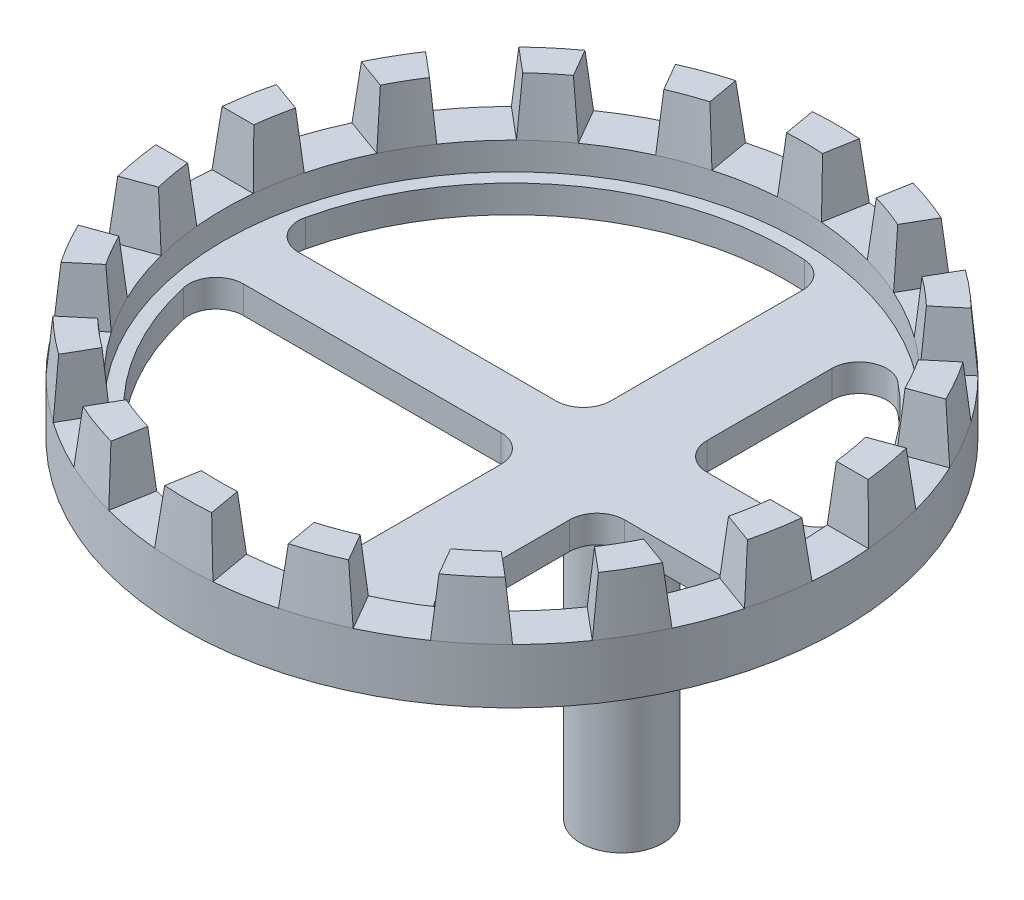
from build123d import *

# Parameters (mm, degrees)
SKETCH1_R                 = 60
SKETCH1_R_2               = 7.5
BOSS_EXTRUDE1_DEPTH       = 5
SKETCH1_3_R               = 7.5
BOSS_EXTRUDE2_DEPTH       = 50
CUT_EXTRUDE1_DEPTH        = 5
SKETCH3_R                 = 60
SKETCH3_R_2               = 52.5
BOSS_EXTRUDE3_DEPTH       = 5
BOSS_EXTRUDE4_DEPTH       = 10
BOSS_EXTRUDE4_DRAFT       = 5
CIRPATTERN1_COPY_1_DEPTH  = 10
CIRPATTERN1_COPY_1_DRAFT  = 5
CIRPATTERN1_COPY_2_DEPTH  = 10
CIRPATTERN1_COPY_2_DRAFT  = 5
CIRPATTERN1_COPY_3_DEPTH  = 10
CIRPATTERN1_COPY_3_DRAFT  = 5
CIRPATTERN1_COPY_4_DEPTH  = 10
CIRPATTERN1_COPY_4_DRAFT  = 5
CIRPATTERN1_COPY_5_DEPTH  = 10
CIRPATTERN1_COPY_5_DRAFT  = 5
CIRPATTERN1_COPY_6_DEPTH  = 10
CIRPATTERN1_COPY_6_DRAFT  = 5
CIRPATTERN1_COPY_7_DEPTH  = 10
CIRPATTERN1_COPY_7_DRAFT  = 5
CIRPATTERN1_COPY_8_DEPTH  = 10
CIRPATTERN1_COPY_8_DRAFT  = 5
CIRPATTERN1_COPY_9_DEPTH  = 10
CIRPATTERN1_COPY_9_DRAFT  = 5
CIRPATTERN1_COPY_10_DEPTH = 10
CIRPATTERN1_COPY_10_DRAFT = 5
CIRPATTERN1_COPY_11_DEPTH = 10
CIRPATTERN1_COPY_11_DRAFT = 5
CIRPATTERN1_COPY_12_DEPTH = 10
CIRPATTERN1_COPY_12_DRAFT = 5
CIRPATTERN1_COPY_13_DEPTH = 10
CIRPATTERN1_COPY_13_DRAFT = 5
CIRPATTERN1_COPY_14_DEPTH = 10
CIRPATTERN1_COPY_14_DRAFT = 5
CIRPATTERN1_COPY_15_DEPTH = 10
CIRPATTERN1_COPY_15_DRAFT = 5
CIRPATTERN1_COPY_16_DEPTH = 10
CIRPATTERN1_COPY_16_DRAFT = 5
CIRPATTERN1_COPY_17_DEPTH = 10
CIRPATTERN1_COPY_17_DRAFT = 5


with BuildPart() as part:
    # Sketch1 → Boss-Extrude1 (new body)
    with BuildSketch(Plane(origin=(0, 0, 0), x_dir=(1, 0, 0), z_dir=(0, 1, 0))):
        with Locations(Location((-20, 0, 0), (0, 0, 270))):
            Circle(SKETCH1_R)
        Circle(SKETCH1_R_2, mode=Mode.SUBTRACT)
        Circle(SKETCH1_R_2)
    extrude(amount=BOSS_EXTRUDE1_DEPTH)

    # Sketch1_3 → Boss-Extrude2 (add)
    with BuildSketch(Plane(origin=(0, 0, 0), x_dir=(1, 0, 0), z_dir=(0, 1, 0))):
        with Locations(Location((0, 0, 0), (0, 0, 270))):
            Circle(SKETCH1_3_R)
    extrude(amount=-BOSS_EXTRUDE2_DEPTH)

    # Sketch2 → Cut-Extrude1 (cut)
    with BuildSketch(Plane(origin=(0, 5, 0), x_dir=(1, 0, 0), z_dir=(0, 1, 0))):
        with BuildLine():
            Line((3, 35.227829908), (3, 12.5))
            ThreePointArc((3, 12.5), (4.464466094, 8.964466094), (8, 7.5))
            Line((8, 7.5), (23.229041164, 7.5))
            ThreePointArc((23.229041164, 7.5), (27.225567434, 9.495373937), (28.032267961, 13.888888889))
            ThreePointArc((28.032267961, 13.888888889), (21.537319816, 27.832554006), (11.111111111, 39.142033231))
            ThreePointArc((11.111111111, 39.142033231), (5.826932532, 39.73091527), (3, 35.227829908))
        make_face()
        with BuildLine():
            Line((-12, 44.899888641), (-12, 10))
            ThreePointArc((-12, 10), (-13.464466094, 6.464466094), (-17, 5))
            Line((-17, 5), (-63.874821937, 5))
            ThreePointArc((-63.874821937, 5), (-67.783501737, 6.881952178), (-68.749802152, 11.111111111))
            ThreePointArc((-68.749802152, 11.111111111), (-49.859513113, 40.104980697), (-16.666666667, 49.888765157))
            ThreePointArc((-16.666666667, 49.888765157), (-13.348516283, 48.315538897), (-12, 44.899888641))
        make_face()
        with BuildLine():
            Line((-17, -5), (-63.874821937, -5))
            ThreePointArc((-63.874821937, -5), (-67.783501737, -6.881952178), (-68.749802152, -11.111111111))
            ThreePointArc((-68.749802152, -11.111111111), (-49.859513113, -40.104980697), (-16.666666667, -49.888765157))
            ThreePointArc((-16.666666667, -49.888765157), (-13.348516283, -48.315538897), (-12, -44.899888641))
            Line((-12, -44.899888641), (-12, -10))
            ThreePointArc((-12, -10), (-13.464466094, -6.464466094), (-17, -5))
        make_face()
        with BuildLine():
            Line((8, -7.5), (29.434299833, -7.5))
            ThreePointArc((29.434299833, -7.5), (23.268873024, -25.056029758), (11.111111111, -39.142033231))
            ThreePointArc((11.111111111, -39.142033231), (5.826932532, -39.73091527), (3, -35.227829908))
            Line((3, -35.227829908), (3, -12.5))
            ThreePointArc((3, -12.5), (4.464466094, -8.964466094), (8, -7.5))
        make_face()
    extrude(amount=-CUT_EXTRUDE1_DEPTH, mode=Mode.SUBTRACT)

    # Sketch3 → Boss-Extrude3 (add)
    with BuildSketch(Plane(origin=(0, 5, 0), x_dir=(1, 0, 0), z_dir=(0, 1, 0))):
        with Locations(Location((-20, 0, 0), (0, 0, 270))):
            Circle(SKETCH3_R)
        with Locations(Location((-20, 0, 0), (0, 0, 270))):
            Circle(SKETCH3_R_2, mode=Mode.SUBTRACT)
    extrude(amount=BOSS_EXTRUDE3_DEPTH)


with BuildPart() as boss_extrude4_tool:
    # Sketch4 → Boss-Extrude4 (with draft: the straight prism first)
    with BuildSketch(Plane(origin=(0, 10, 0), x_dir=(1, 0, 0), z_dir=(0, 1, 0))):
        with BuildLine():
            Line((-25.307880973, 59.764758843), (-24, 52.347397261))
            ThreePointArc((-24, 52.347397261), (-20, 52.5), (-16, 52.347397261))
            Line((-16, 52.347397261), (-14.692119027, 59.764758843))
            ThreePointArc((-14.692119027, 59.764758843), (-20, 60), (-25.307880973, 59.764758843))
        make_face()
    extrude(amount=BOSS_EXTRUDE4_DEPTH)
    # Boss-Extrude4: the draft: its side faces are tilted about the plane it starts from
    boss_extrude4_sides = [boss_extrude4_tool.faces().sort_by_distance(p)[0] for p in [
        (-15.346059514, 15, -56.056078052),
        (-20, 15, -60),
        (-24.653940486, 15, -56.056078052),
        (-20, 15, -52.5),
    ]]
    draft(boss_extrude4_sides, Plane(origin=(0, 10, 0), x_dir=(1, 0, 0), z_dir=(0, 1, 0)), BOSS_EXTRUDE4_DRAFT)


with BuildPart() as part_1:
    add(part.part)

    # Boss-Extrude4: add boss_extrude4_tool
    add(boss_extrude4_tool.part)


with BuildPart() as cirpattern1_copy_1_tool:
    # CirPattern1 copy 1 sketch → CirPattern1 copy 1 (with draft: the straight prism first)
    with BuildSketch(Plane(origin=(-1.206147584, 10, -6.840402867), x_dir=(0.9396926207859084, 0, -0.3420201433256687), z_dir=(0, 1, 0))):
        with BuildLine():
            Line((-25.307880973, 59.764758843), (-24, 52.347397261))
            ThreePointArc((-24, 52.347397261), (-20, 52.5), (-16, 52.347397261))
            Line((-16, 52.347397261), (-14.692119027, 59.764758843))
            ThreePointArc((-14.692119027, 59.764758843), (-20, 60), (-25.307880973, 59.764758843))
        make_face()
    extrude(amount=CIRPATTERN1_COPY_1_DEPTH)
    # CirPattern1 copy 1: the draft: its side faces are tilted about the plane it starts from
    cirpattern1_copy_1_sides = [cirpattern1_copy_1_tool.faces().sort_by_distance(p)[0] for p in [
        (-34.799034317, 15, -54.267224288),
        (-40.5212086, 15, -56.381557247),
        (-43.545581382, 15, -51.083741504),
        (-37.956057525, 15, -49.333862591),
    ]]
    draft(cirpattern1_copy_1_sides, Plane(origin=(-1.206147584, 10, -6.840402867), x_dir=(0.9396926207859084, 0, -0.3420201433256687), z_dir=(0, 1, 0)), CIRPATTERN1_COPY_1_DRAFT)


with BuildPart() as part_2:
    add(part_1.part)

    # CirPattern1 copy 1: add cirpattern1_copy_1_tool
    add(cirpattern1_copy_1_tool.part)


with BuildPart() as cirpattern1_copy_2_tool:
    # CirPattern1 copy 2 sketch → CirPattern1 copy 2 (with draft: the straight prism first)
    with BuildSketch(Plane(origin=(-4.679111138, 10, -12.855752194), x_dir=(0.766044443118978, 0, -0.6427876096865393), z_dir=(0, 1, 0))):
        with BuildLine():
            Line((-25.307880973, 59.764758843), (-24, 52.347397261))
            ThreePointArc((-24, 52.347397261), (-20, 52.5), (-16, 52.347397261))
            Line((-16, 52.347397261), (-14.692119027, 59.764758843))
            ThreePointArc((-14.692119027, 59.764758843), (-20, 60), (-25.307880973, 59.764758843))
        make_face()
    extrude(amount=CIRPATTERN1_COPY_2_DEPTH)
    # CirPattern1 copy 2: the draft: its side faces are tilted about the plane it starts from
    cirpattern1_copy_2_sides = [cirpattern1_copy_2_tool.faces().sort_by_distance(p)[0] for p in [
        (-52.467027172, 15, -45.932942375),
        (-58.567256581, 15, -45.962666587),
        (-59.597277667, 15, -39.949951814),
        (-53.746349509, 15, -40.217333264),
    ]]
    draft(cirpattern1_copy_2_sides, Plane(origin=(-4.679111138, 10, -12.855752194), x_dir=(0.766044443118978, 0, -0.6427876096865393), z_dir=(0, 1, 0)), CIRPATTERN1_COPY_2_DRAFT)


with BuildPart() as part_3:
    add(part_2.part)

    # CirPattern1 copy 2: add cirpattern1_copy_2_tool
    add(cirpattern1_copy_2_tool.part)


with BuildPart() as cirpattern1_copy_3_tool:
    # CirPattern1 copy 3 sketch → CirPattern1 copy 3 (with draft: the straight prism first)
    with BuildSketch(Plane(origin=(-10, 10, -17.320508076), x_dir=(0.5000000000000001, 0, -0.8660254037844386), z_dir=(0, 1, 0))):
        with BuildLine():
            Line((-25.307880973, 59.764758843), (-24, 52.347397261))
            ThreePointArc((-24, 52.347397261), (-20, 52.5), (-16, 52.347397261))
            Line((-16, 52.347397261), (-14.692119027, 59.764758843))
            ThreePointArc((-14.692119027, 59.764758843), (-20, 60), (-25.307880973, 59.764758843))
        make_face()
    extrude(amount=CIRPATTERN1_COPY_3_DEPTH)
    # CirPattern1 copy 3: the draft: its side faces are tilted about the plane it starts from
    cirpattern1_copy_3_sides = [cirpattern1_copy_3_tool.faces().sort_by_distance(p)[0] for p in [
        (-66.219017387, 15, -32.058469715),
        (-71.961524227, 15, -30),
        (-70.872957873, 15, -23.997608337),
        (-65.466333699, 15, -26.25),
    ]]
    draft(cirpattern1_copy_3_sides, Plane(origin=(-10, 10, -17.320508076), x_dir=(0.5000000000000001, 0, -0.8660254037844386), z_dir=(0, 1, 0)), CIRPATTERN1_COPY_3_DRAFT)


with BuildPart() as part_4:
    add(part_3.part)

    # CirPattern1 copy 3: add cirpattern1_copy_3_tool
    add(cirpattern1_copy_3_tool.part)


with BuildPart() as cirpattern1_copy_4_tool:
    # CirPattern1 copy 4 sketch → CirPattern1 copy 4 (with draft: the straight prism first)
    with BuildSketch(Plane(origin=(-16.527036447, 10, -19.69615506), x_dir=(0.17364817766693041, 0, -0.984807753012208), z_dir=(0, 1, 0))):
        with BuildLine():
            Line((-25.307880973, 59.764758843), (-24, 52.347397261))
            ThreePointArc((-24, 52.347397261), (-20, 52.5), (-16, 52.347397261))
            Line((-16, 52.347397261), (-14.692119027, 59.764758843))
            ThreePointArc((-14.692119027, 59.764758843), (-20, 60), (-25.307880973, 59.764758843))
        make_face()
    extrude(amount=CIRPATTERN1_COPY_4_DEPTH)
    # CirPattern1 copy 4: the draft: its side faces are tilted about the plane it starts from
    cirpattern1_copy_4_sides = [cirpattern1_copy_4_tool.faces().sort_by_distance(p)[0] for p in [
        (-74.396311985, 15, -14.317272474),
        (-79.088465181, 15, -10.41889066),
        (-76.012608553, 15, -5.150799128),
        (-71.702407033, 15, -9.116529328),
    ]]
    draft(cirpattern1_copy_4_sides, Plane(origin=(-16.527036447, 10, -19.69615506), x_dir=(0.17364817766693041, 0, -0.984807753012208), z_dir=(0, 1, 0)), CIRPATTERN1_COPY_4_DRAFT)


with BuildPart() as part_5:
    add(part_4.part)

    # CirPattern1 copy 4: add cirpattern1_copy_4_tool
    add(cirpattern1_copy_4_tool.part)


with BuildPart() as cirpattern1_copy_5_tool:
    # CirPattern1 copy 5 sketch → CirPattern1 copy 5 (with draft: the straight prism first)
    with BuildSketch(Plane(origin=(-23.472963553, 10, -19.69615506), x_dir=(-0.1736481776669303, 0, -0.984807753012208), z_dir=(0, 1, 0))):
        with BuildLine():
            Line((-25.307880973, 59.764758843), (-24, 52.347397261))
            ThreePointArc((-24, 52.347397261), (-20, 52.5), (-16, 52.347397261))
            Line((-16, 52.347397261), (-14.692119027, 59.764758843))
            ThreePointArc((-14.692119027, 59.764758843), (-20, 60), (-25.307880973, 59.764758843))
        make_face()
    extrude(amount=CIRPATTERN1_COPY_5_DEPTH)
    # CirPattern1 copy 5: the draft: its side faces are tilted about the plane it starts from
    cirpattern1_copy_5_sides = [cirpattern1_copy_5_tool.faces().sort_by_distance(p)[0] for p in [
        (-76.012608553, 15, 5.150799128),
        (-79.088465181, 15, 10.41889066),
        (-74.396311985, 15, 14.317272474),
        (-71.702407033, 15, 9.116529328),
    ]]
    draft(cirpattern1_copy_5_sides, Plane(origin=(-23.472963553, 10, -19.69615506), x_dir=(-0.1736481776669303, 0, -0.984807753012208), z_dir=(0, 1, 0)), CIRPATTERN1_COPY_5_DRAFT)


with BuildPart() as part_6:
    add(part_5.part)

    # CirPattern1 copy 5: add cirpattern1_copy_5_tool
    add(cirpattern1_copy_5_tool.part)


with BuildPart() as cirpattern1_copy_6_tool:
    # CirPattern1 copy 6 sketch → CirPattern1 copy 6 (with draft: the straight prism first)
    with BuildSketch(Plane(origin=(-30, 10, -17.320508076), x_dir=(-0.4999999999999998, 0, -0.8660254037844387), z_dir=(0, 1, 0))):
        with BuildLine():
            Line((-25.307880973, 59.764758843), (-24, 52.347397261))
            ThreePointArc((-24, 52.347397261), (-20, 52.5), (-16, 52.347397261))
            Line((-16, 52.347397261), (-14.692119027, 59.764758843))
            ThreePointArc((-14.692119027, 59.764758843), (-20, 60), (-25.307880973, 59.764758843))
        make_face()
    extrude(amount=CIRPATTERN1_COPY_6_DEPTH)
    # CirPattern1 copy 6: the draft: its side faces are tilted about the plane it starts from
    cirpattern1_copy_6_sides = [cirpattern1_copy_6_tool.faces().sort_by_distance(p)[0] for p in [
        (-70.872957873, 15, 23.997608337),
        (-71.961524227, 15, 30),
        (-66.219017387, 15, 32.058469715),
        (-65.466333699, 15, 26.25),
    ]]
    draft(cirpattern1_copy_6_sides, Plane(origin=(-30, 10, -17.320508076), x_dir=(-0.4999999999999998, 0, -0.8660254037844387), z_dir=(0, 1, 0)), CIRPATTERN1_COPY_6_DRAFT)


with BuildPart() as part_7:
    add(part_6.part)

    # CirPattern1 copy 6: add cirpattern1_copy_6_tool
    add(cirpattern1_copy_6_tool.part)


with BuildPart() as cirpattern1_copy_7_tool:
    # CirPattern1 copy 7 sketch → CirPattern1 copy 7 (with draft: the straight prism first)
    with BuildSketch(Plane(origin=(-35.320888862, 10, -12.855752194), x_dir=(-0.7660444431189779, 0, -0.6427876096865395), z_dir=(0, 1, 0))):
        with BuildLine():
            Line((-25.307880973, 59.764758843), (-24, 52.347397261))
            ThreePointArc((-24, 52.347397261), (-20, 52.5), (-16, 52.347397261))
            Line((-16, 52.347397261), (-14.692119027, 59.764758843))
            ThreePointArc((-14.692119027, 59.764758843), (-20, 60), (-25.307880973, 59.764758843))
        make_face()
    extrude(amount=CIRPATTERN1_COPY_7_DEPTH)
    # CirPattern1 copy 7: the draft: its side faces are tilted about the plane it starts from
    cirpattern1_copy_7_sides = [cirpattern1_copy_7_tool.faces().sort_by_distance(p)[0] for p in [
        (-59.597277667, 15, 39.949951814),
        (-58.567256581, 15, 45.962666587),
        (-52.467027172, 15, 45.932942375),
        (-53.746349509, 15, 40.217333264),
    ]]
    draft(cirpattern1_copy_7_sides, Plane(origin=(-35.320888862, 10, -12.855752194), x_dir=(-0.7660444431189779, 0, -0.6427876096865395), z_dir=(0, 1, 0)), CIRPATTERN1_COPY_7_DRAFT)


with BuildPart() as part_8:
    add(part_7.part)

    # CirPattern1 copy 7: add cirpattern1_copy_7_tool
    add(cirpattern1_copy_7_tool.part)


with BuildPart() as cirpattern1_copy_8_tool:
    # CirPattern1 copy 8 sketch → CirPattern1 copy 8 (with draft: the straight prism first)
    with BuildSketch(Plane(origin=(-38.793852416, 10, -6.840402867), x_dir=(-0.9396926207859083, 0, -0.3420201433256689), z_dir=(0, 1, 0))):
        with BuildLine():
            Line((-25.307880973, 59.764758843), (-24, 52.347397261))
            ThreePointArc((-24, 52.347397261), (-20, 52.5), (-16, 52.347397261))
            Line((-16, 52.347397261), (-14.692119027, 59.764758843))
            ThreePointArc((-14.692119027, 59.764758843), (-20, 60), (-25.307880973, 59.764758843))
        make_face()
    extrude(amount=CIRPATTERN1_COPY_8_DEPTH)
    # CirPattern1 copy 8: the draft: its side faces are tilted about the plane it starts from
    cirpattern1_copy_8_sides = [cirpattern1_copy_8_tool.faces().sort_by_distance(p)[0] for p in [
        (-43.545581382, 15, 51.083741504),
        (-40.5212086, 15, 56.381557247),
        (-34.799034317, 15, 54.267224288),
        (-37.956057525, 15, 49.333862591),
    ]]
    draft(cirpattern1_copy_8_sides, Plane(origin=(-38.793852416, 10, -6.840402867), x_dir=(-0.9396926207859083, 0, -0.3420201433256689), z_dir=(0, 1, 0)), CIRPATTERN1_COPY_8_DRAFT)


with BuildPart() as part_9:
    add(part_8.part)

    # CirPattern1 copy 8: add cirpattern1_copy_8_tool
    add(cirpattern1_copy_8_tool.part)


with BuildPart() as cirpattern1_copy_9_tool:
    # CirPattern1 copy 9 sketch → CirPattern1 copy 9 (with draft: the straight prism first)
    with BuildSketch(Plane(origin=(-40, 10, 0), x_dir=(-1, 0, 0), z_dir=(0, 1, 0))):
        with BuildLine():
            Line((-25.307880973, 59.764758843), (-24, 52.347397261))
            ThreePointArc((-24, 52.347397261), (-20, 52.5), (-16, 52.347397261))
            Line((-16, 52.347397261), (-14.692119027, 59.764758843))
            ThreePointArc((-14.692119027, 59.764758843), (-20, 60), (-25.307880973, 59.764758843))
        make_face()
    extrude(amount=CIRPATTERN1_COPY_9_DEPTH)
    # CirPattern1 copy 9: the draft: its side faces are tilted about the plane it starts from
    cirpattern1_copy_9_sides = [cirpattern1_copy_9_tool.faces().sort_by_distance(p)[0] for p in [
        (-24.653940486, 15, 56.056078052),
        (-20, 15, 60),
        (-15.346059514, 15, 56.056078052),
        (-20, 15, 52.5),
    ]]
    draft(cirpattern1_copy_9_sides, Plane(origin=(-40, 10, 0), x_dir=(-1, 0, 0), z_dir=(0, 1, 0)), CIRPATTERN1_COPY_9_DRAFT)


with BuildPart() as part_10:
    add(part_9.part)

    # CirPattern1 copy 9: add cirpattern1_copy_9_tool
    add(cirpattern1_copy_9_tool.part)


with BuildPart() as cirpattern1_copy_10_tool:
    # CirPattern1 copy 10 sketch → CirPattern1 copy 10 (with draft: the straight prism first)
    with BuildSketch(Plane(origin=(-38.793852416, 10, 6.840402867), x_dir=(-0.9396926207859084, 0, 0.34202014332566866), z_dir=(0, 1, 0))):
        with BuildLine():
            Line((-25.307880973, 59.764758843), (-24, 52.347397261))
            ThreePointArc((-24, 52.347397261), (-20, 52.5), (-16, 52.347397261))
            Line((-16, 52.347397261), (-14.692119027, 59.764758843))
            ThreePointArc((-14.692119027, 59.764758843), (-20, 60), (-25.307880973, 59.764758843))
        make_face()
    extrude(amount=CIRPATTERN1_COPY_10_DEPTH)
    # CirPattern1 copy 10: the draft: its side faces are tilted about the plane it starts from
    cirpattern1_copy_10_sides = [cirpattern1_copy_10_tool.faces().sort_by_distance(p)[0] for p in [
        (-5.200965683, 15, 54.267224288),
        (0.5212086, 15, 56.381557247),
        (3.545581382, 15, 51.083741504),
        (-2.043942475, 15, 49.333862591),
    ]]
    draft(cirpattern1_copy_10_sides, Plane(origin=(-38.793852416, 10, 6.840402867), x_dir=(-0.9396926207859084, 0, 0.34202014332566866), z_dir=(0, 1, 0)), CIRPATTERN1_COPY_10_DRAFT)


with BuildPart() as part_11:
    add(part_10.part)

    # CirPattern1 copy 10: add cirpattern1_copy_10_tool
    add(cirpattern1_copy_10_tool.part)


with BuildPart() as cirpattern1_copy_11_tool:
    # CirPattern1 copy 11 sketch → CirPattern1 copy 11 (with draft: the straight prism first)
    with BuildSketch(Plane(origin=(-35.320888862, 10, 12.855752194), x_dir=(-0.766044443118978, 0, 0.6427876096865393), z_dir=(0, 1, 0))):
        with BuildLine():
            Line((-25.307880973, 59.764758843), (-24, 52.347397261))
            ThreePointArc((-24, 52.347397261), (-20, 52.5), (-16, 52.347397261))
            Line((-16, 52.347397261), (-14.692119027, 59.764758843))
            ThreePointArc((-14.692119027, 59.764758843), (-20, 60), (-25.307880973, 59.764758843))
        make_face()
    extrude(amount=CIRPATTERN1_COPY_11_DEPTH)
    # CirPattern1 copy 11: the draft: its side faces are tilted about the plane it starts from
    cirpattern1_copy_11_sides = [cirpattern1_copy_11_tool.faces().sort_by_distance(p)[0] for p in [
        (12.467027172, 15, 45.932942375),
        (18.567256581, 15, 45.962666587),
        (19.597277667, 15, 39.949951814),
        (13.746349509, 15, 40.217333264),
    ]]
    draft(cirpattern1_copy_11_sides, Plane(origin=(-35.320888862, 10, 12.855752194), x_dir=(-0.766044443118978, 0, 0.6427876096865393), z_dir=(0, 1, 0)), CIRPATTERN1_COPY_11_DRAFT)


with BuildPart() as part_12:
    add(part_11.part)

    # CirPattern1 copy 11: add cirpattern1_copy_11_tool
    add(cirpattern1_copy_11_tool.part)


with BuildPart() as cirpattern1_copy_12_tool:
    # CirPattern1 copy 12 sketch → CirPattern1 copy 12 (with draft: the straight prism first)
    with BuildSketch(Plane(origin=(-30, 10, 17.320508076), x_dir=(-0.5000000000000004, 0, 0.8660254037844384), z_dir=(0, 1, 0))):
        with BuildLine():
            Line((-25.307880973, 59.764758843), (-24, 52.347397261))
            ThreePointArc((-24, 52.347397261), (-20, 52.5), (-16, 52.347397261))
            Line((-16, 52.347397261), (-14.692119027, 59.764758843))
            ThreePointArc((-14.692119027, 59.764758843), (-20, 60), (-25.307880973, 59.764758843))
        make_face()
    extrude(amount=CIRPATTERN1_COPY_12_DEPTH)
    # CirPattern1 copy 12: the draft: its side faces are tilted about the plane it starts from
    cirpattern1_copy_12_sides = [cirpattern1_copy_12_tool.faces().sort_by_distance(p)[0] for p in [
        (26.219017387, 15, 32.058469715),
        (31.961524227, 15, 30),
        (30.872957873, 15, 23.997608337),
        (25.466333699, 15, 26.25),
    ]]
    draft(cirpattern1_copy_12_sides, Plane(origin=(-30, 10, 17.320508076), x_dir=(-0.5000000000000004, 0, 0.8660254037844384), z_dir=(0, 1, 0)), CIRPATTERN1_COPY_12_DRAFT)


with BuildPart() as part_13:
    add(part_12.part)

    # CirPattern1 copy 12: add cirpattern1_copy_12_tool
    add(cirpattern1_copy_12_tool.part)


with BuildPart() as cirpattern1_copy_13_tool:
    # CirPattern1 copy 13 sketch → CirPattern1 copy 13 (with draft: the straight prism first)
    with BuildSketch(Plane(origin=(-23.472963553, 10, 19.69615506), x_dir=(-0.17364817766693033, 0, 0.984807753012208), z_dir=(0, 1, 0))):
        with BuildLine():
            Line((-25.307880973, 59.764758843), (-24, 52.347397261))
            ThreePointArc((-24, 52.347397261), (-20, 52.5), (-16, 52.347397261))
            Line((-16, 52.347397261), (-14.692119027, 59.764758843))
            ThreePointArc((-14.692119027, 59.764758843), (-20, 60), (-25.307880973, 59.764758843))
        make_face()
    extrude(amount=CIRPATTERN1_COPY_13_DEPTH)
    # CirPattern1 copy 13: the draft: its side faces are tilted about the plane it starts from
    cirpattern1_copy_13_sides = [cirpattern1_copy_13_tool.faces().sort_by_distance(p)[0] for p in [
        (34.396311985, 15, 14.317272474),
        (39.088465181, 15, 10.41889066),
        (36.012608553, 15, 5.150799128),
        (31.702407033, 15, 9.116529328),
    ]]
    draft(cirpattern1_copy_13_sides, Plane(origin=(-23.472963553, 10, 19.69615506), x_dir=(-0.17364817766693033, 0, 0.984807753012208), z_dir=(0, 1, 0)), CIRPATTERN1_COPY_13_DRAFT)


with BuildPart() as part_14:
    add(part_13.part)

    # CirPattern1 copy 13: add cirpattern1_copy_13_tool
    add(cirpattern1_copy_13_tool.part)


with BuildPart() as cirpattern1_copy_14_tool:
    # CirPattern1 copy 14 sketch → CirPattern1 copy 14 (with draft: the straight prism first)
    with BuildSketch(Plane(origin=(-16.527036447, 10, 19.69615506), x_dir=(0.17364817766692997, 0, 0.9848077530122081), z_dir=(0, 1, 0))):
        with BuildLine():
            Line((-25.307880973, 59.764758843), (-24, 52.347397261))
            ThreePointArc((-24, 52.347397261), (-20, 52.5), (-16, 52.347397261))
            Line((-16, 52.347397261), (-14.692119027, 59.764758843))
            ThreePointArc((-14.692119027, 59.764758843), (-20, 60), (-25.307880973, 59.764758843))
        make_face()
    extrude(amount=CIRPATTERN1_COPY_14_DEPTH)
    # CirPattern1 copy 14: the draft: its side faces are tilted about the plane it starts from
    cirpattern1_copy_14_sides = [cirpattern1_copy_14_tool.faces().sort_by_distance(p)[0] for p in [
        (36.012608553, 15, -5.150799128),
        (39.088465181, 15, -10.41889066),
        (34.396311985, 15, -14.317272474),
        (31.702407033, 15, -9.116529328),
    ]]
    draft(cirpattern1_copy_14_sides, Plane(origin=(-16.527036447, 10, 19.69615506), x_dir=(0.17364817766692997, 0, 0.9848077530122081), z_dir=(0, 1, 0)), CIRPATTERN1_COPY_14_DRAFT)


with BuildPart() as part_15:
    add(part_14.part)

    # CirPattern1 copy 14: add cirpattern1_copy_14_tool
    add(cirpattern1_copy_14_tool.part)


with BuildPart() as cirpattern1_copy_15_tool:
    # CirPattern1 copy 15 sketch → CirPattern1 copy 15 (with draft: the straight prism first)
    with BuildSketch(Plane(origin=(-10, 10, 17.320508076), x_dir=(0.5000000000000001, 0, 0.8660254037844386), z_dir=(0, 1, 0))):
        with BuildLine():
            Line((-25.307880973, 59.764758843), (-24, 52.347397261))
            ThreePointArc((-24, 52.347397261), (-20, 52.5), (-16, 52.347397261))
            Line((-16, 52.347397261), (-14.692119027, 59.764758843))
            ThreePointArc((-14.692119027, 59.764758843), (-20, 60), (-25.307880973, 59.764758843))
        make_face()
    extrude(amount=CIRPATTERN1_COPY_15_DEPTH)
    # CirPattern1 copy 15: the draft: its side faces are tilted about the plane it starts from
    cirpattern1_copy_15_sides = [cirpattern1_copy_15_tool.faces().sort_by_distance(p)[0] for p in [
        (30.872957873, 15, -23.997608337),
        (31.961524227, 15, -30),
        (26.219017387, 15, -32.058469715),
        (25.466333699, 15, -26.25),
    ]]
    draft(cirpattern1_copy_15_sides, Plane(origin=(-10, 10, 17.320508076), x_dir=(0.5000000000000001, 0, 0.8660254037844386), z_dir=(0, 1, 0)), CIRPATTERN1_COPY_15_DRAFT)


with BuildPart() as part_16:
    add(part_15.part)

    # CirPattern1 copy 15: add cirpattern1_copy_15_tool
    add(cirpattern1_copy_15_tool.part)


with BuildPart() as cirpattern1_copy_16_tool:
    # CirPattern1 copy 16 sketch → CirPattern1 copy 16 (with draft: the straight prism first)
    with BuildSketch(Plane(origin=(-4.679111138, 10, 12.855752194), x_dir=(0.7660444431189778, 0, 0.6427876096865396), z_dir=(0, 1, 0))):
        with BuildLine():
            Line((-25.307880973, 59.764758843), (-24, 52.347397261))
            ThreePointArc((-24, 52.347397261), (-20, 52.5), (-16, 52.347397261))
            Line((-16, 52.347397261), (-14.692119027, 59.764758843))
            ThreePointArc((-14.692119027, 59.764758843), (-20, 60), (-25.307880973, 59.764758843))
        make_face()
    extrude(amount=CIRPATTERN1_COPY_16_DEPTH)
    # CirPattern1 copy 16: the draft: its side faces are tilted about the plane it starts from
    cirpattern1_copy_16_sides = [cirpattern1_copy_16_tool.faces().sort_by_distance(p)[0] for p in [
        (19.597277667, 15, -39.949951814),
        (18.567256581, 15, -45.962666587),
        (12.467027172, 15, -45.932942375),
        (13.746349509, 15, -40.217333264),
    ]]
    draft(cirpattern1_copy_16_sides, Plane(origin=(-4.679111138, 10, 12.855752194), x_dir=(0.7660444431189778, 0, 0.6427876096865396), z_dir=(0, 1, 0)), CIRPATTERN1_COPY_16_DRAFT)


with BuildPart() as part_17:
    add(part_16.part)

    # CirPattern1 copy 16: add cirpattern1_copy_16_tool
    add(cirpattern1_copy_16_tool.part)


with BuildPart() as cirpattern1_copy_17_tool:
    # CirPattern1 copy 17 sketch → CirPattern1 copy 17 (with draft: the straight prism first)
    with BuildSketch(Plane(origin=(-1.206147584, 10, 6.840402867), x_dir=(0.9396926207859084, 0, 0.3420201433256686), z_dir=(0, 1, 0))):
        with BuildLine():
            Line((-25.307880973, 59.764758843), (-24, 52.347397261))
            ThreePointArc((-24, 52.347397261), (-20, 52.5), (-16, 52.347397261))
            Line((-16, 52.347397261), (-14.692119027, 59.764758843))
            ThreePointArc((-14.692119027, 59.764758843), (-20, 60), (-25.307880973, 59.764758843))
        make_face()
    extrude(amount=CIRPATTERN1_COPY_17_DEPTH)
    # CirPattern1 copy 17: the draft: its side faces are tilted about the plane it starts from
    cirpattern1_copy_17_sides = [cirpattern1_copy_17_tool.faces().sort_by_distance(p)[0] for p in [
        (3.545581382, 15, -51.083741504),
        (0.5212086, 15, -56.381557247),
        (-5.200965683, 15, -54.267224288),
        (-2.043942475, 15, -49.333862591),
    ]]
    draft(cirpattern1_copy_17_sides, Plane(origin=(-1.206147584, 10, 6.840402867), x_dir=(0.9396926207859084, 0, 0.3420201433256686), z_dir=(0, 1, 0)), CIRPATTERN1_COPY_17_DRAFT)


with BuildPart() as part_18:
    add(part_17.part)

    # CirPattern1 copy 17: add cirpattern1_copy_17_tool
    add(cirpattern1_copy_17_tool.part)


solid = part_18.part
